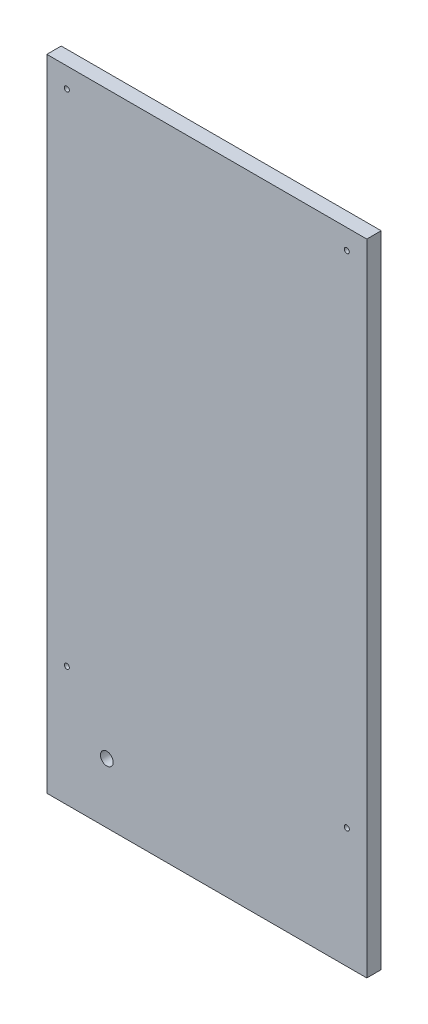
from build123d import *

# Parameters (mm, degrees)
SKETCH1_W            = 400
SKETCH1_H            = 800
BASE_DEPTH           = 18
SKETCH2_R            = 3.15
MOUNTING_HOLES_DEPTH = 895.608294171
TAP_HOLE_REACH       = 896.608
SKETCH4_R            = 8


with BuildPart() as part:
    # Sketch1 → Base (new body)
    with BuildSketch(Plane.XY):
        with Locations((200, 400)):
            Rectangle(SKETCH1_W, SKETCH1_H)
    extrude(amount=BASE_DEPTH)

    # Sketch2 → Mounting holes (cut, through all)
    with BuildSketch(Plane.XY.offset(18)):
        with Locations((25, 775)):
            Circle(SKETCH2_R)
        with Locations((375, 775)):
            Circle(SKETCH2_R)
        with Locations((25, 150)):
            Circle(SKETCH2_R)
        with Locations((375, 150)):
            Circle(SKETCH2_R)
    extrude(amount=-MOUNTING_HOLES_DEPTH, mode=Mode.SUBTRACT)

    # Sketch4 → Tap hole (cut, up to next)
    with BuildSketch(Plane(origin=(0, 0, 0), x_dir=(-1, 0, 0), z_dir=(0, 0, -1)), mode=Mode.PRIVATE) as tap_hole_sk1:
        with Locations((-75, 75)):
            Circle(SKETCH4_R)
    tap_hole_tool1 = extrude(tap_hole_sk1.sketch, amount=-TAP_HOLE_REACH, mode=Mode.PRIVATE) & part.part
    add(tap_hole_tool1.solids().sort_by_distance((75, 75, 0))[0], mode=Mode.SUBTRACT)


solid = part.part
